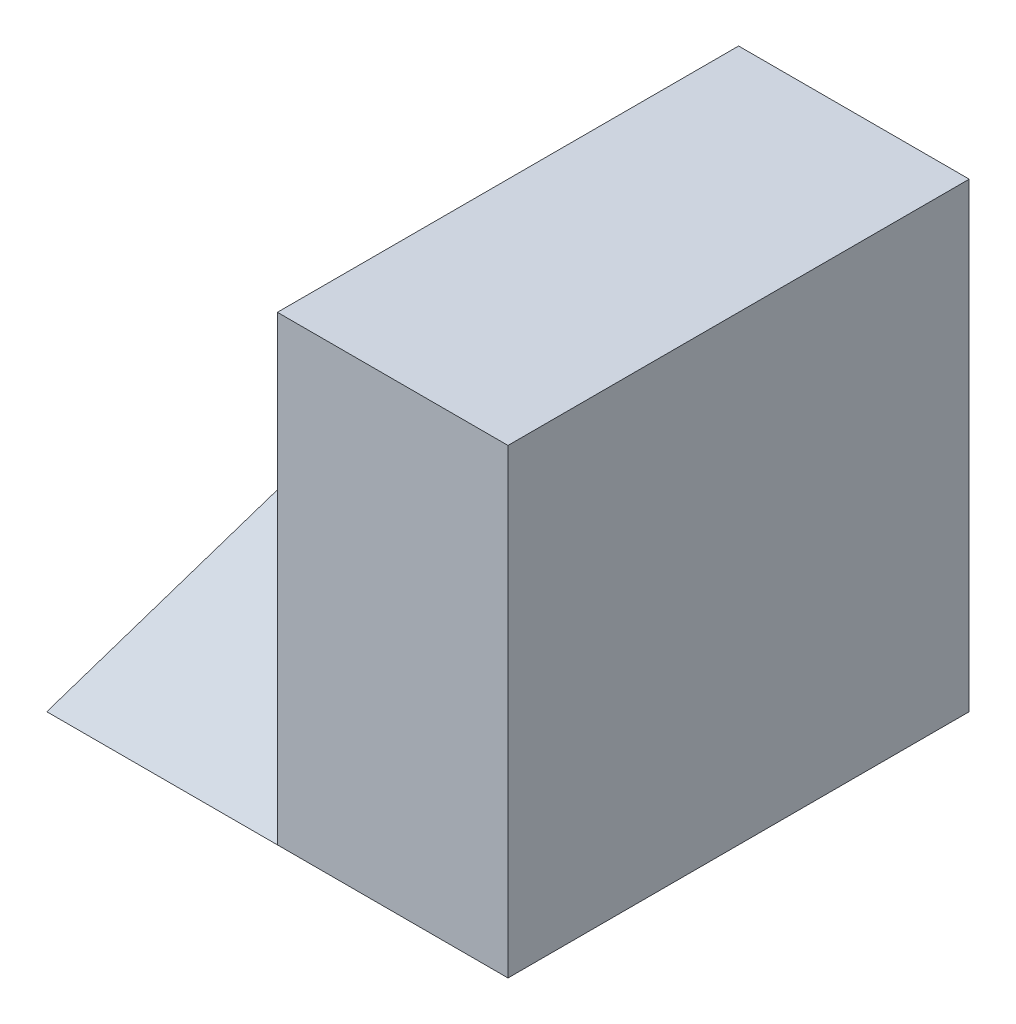
from build123d import *

# Parameters (mm, degrees)
SKETCH1_W           = 40
SKETCH1_H           = 40
BOSS_EXTRUDE1_DEPTH = 40
CUT_EXTRUDE1_DEPTH  = 40
CUT_EXTRUDE4_DEPTH  = 20
CUT_EXTRUDE5_DEPTH  = 20
BOSS_EXTRUDE2_DEPTH = 20
CUT_EXTRUDE6_DEPTH  = 50


with BuildPart() as part:
    # Sketch1 → Boss-Extrude1 (new body)
    with BuildSketch(Plane.XY):
        with Locations((20, 20)):
            Rectangle(SKETCH1_W, SKETCH1_H)
    extrude(amount=BOSS_EXTRUDE1_DEPTH)

    # Sketch2 → Cut-Extrude1 (cut)
    with BuildSketch(Plane.XY.offset(40)):
        Polygon((0, 0), (20, 40), (0, 40), align=None)
    extrude(amount=-CUT_EXTRUDE1_DEPTH, mode=Mode.SUBTRACT)

    # Sketch7 → Cut-Extrude4 (cut)
    with BuildSketch(Plane.XY.offset(40)):
        Polygon((20, 40), (20, 0), (0, 0), align=None)
    extrude(amount=-CUT_EXTRUDE4_DEPTH, mode=Mode.SUBTRACT)

    # Sketch8 → Cut-Extrude5 (cut)
    with BuildSketch(Plane.XY.offset(20)):
        Polygon((20, 40), (0, 0), (20, 0), align=None)
    extrude(amount=-CUT_EXTRUDE5_DEPTH, mode=Mode.SUBTRACT)

    # Sketch9 → Boss-Extrude2 (add)
    with BuildSketch(Plane.ZY.offset(-20)):
        Polygon((0, 40), (40, 0), (0, 0), align=None)
    extrude(amount=BOSS_EXTRUDE2_DEPTH)

    # Sketch10 → Cut-Extrude6 (cut)
    with BuildSketch(Plane(origin=(0, 0, 0), x_dir=(-1, 0, 0), z_dir=(0, 0, -1))):
        Polygon((0, 0), (-20, 40), (0, 40), align=None)
    extrude(amount=-CUT_EXTRUDE6_DEPTH, mode=Mode.SUBTRACT)


solid = part.part
